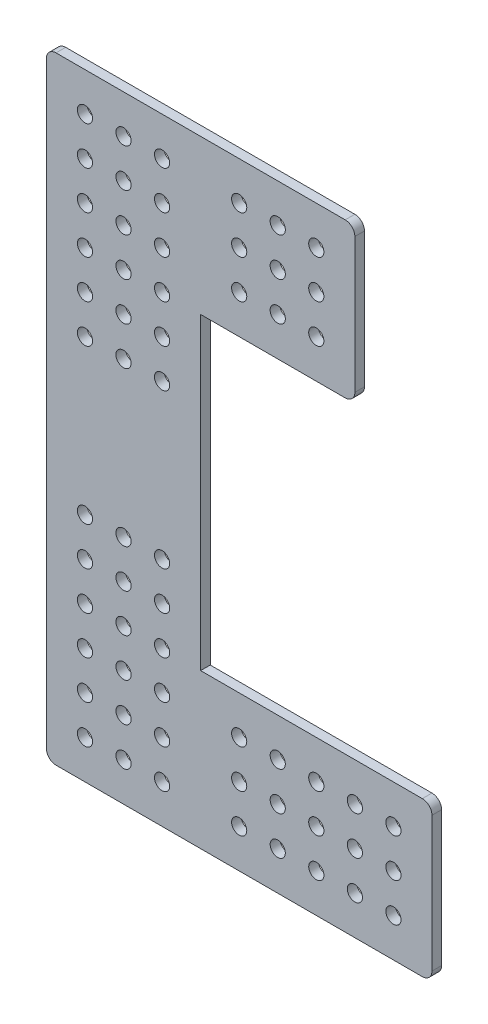
from build123d import *

# Parameters (mm, degrees)
BOSS_EXTRUDE1_DEPTH = 3.175
SKETCH2_R           = 2.5
CUT_EXTRUDE1_DEPTH  = 4.175
BOSS_EXTRUDE2_DEPTH = 3.175
SKETCH4_R           = 2.505
CUT_EXTRUDE2_DEPTH  = 4.175


with BuildPart() as part:
    # Sketch1 → Boss-Extrude1 (new body)
    with BuildSketch(Plane.XY):
        with BuildLine():
            Line((26.334969325, 167.047852761), (23.159969325, 167.047852761))
            Line((23.159969325, 167.047852761), (-21.290030675, 167.047852761))
            ThreePointArc((-21.290030675, 167.047852761), (-23.535094705, 166.117916791), (-24.465030675, 163.872852761))
            Line((-24.465030675, 163.872852761), (-24.465030675, 14.647852761))
            Line((-24.465030675, 14.647852761), (26.334969325, 14.647852761))
            Line((26.334969325, 14.647852761), (26.334969325, 163.872852761))
            Line((26.334969325, 163.872852761), (26.334969325, 167.047852761))
        make_face()
        with BuildLine():
            Line((99.359969325, 14.647852761), (26.334969325, 14.647852761))
            Line((26.334969325, 14.647852761), (-24.465030675, 14.647852761))
            Line((-24.465030675, 14.647852761), (-24.465030675, -32.977147239))
            ThreePointArc((-24.465030675, -32.977147239), (-23.535094705, -35.22221127), (-21.290030675, -36.152147239))
            Line((-21.290030675, -36.152147239), (99.359969325, -36.152147239))
            ThreePointArc((99.359969325, -36.152147239), (101.605033355, -35.22221127), (102.534969325, -32.977147239))
            Line((102.534969325, -32.977147239), (102.534969325, 11.472852761))
            ThreePointArc((102.534969325, 11.472852761), (101.605033355, 13.717916791), (99.359969325, 14.647852761))
        make_face()
    extrude(amount=BOSS_EXTRUDE1_DEPTH)

    # Sketch2 → Cut-Extrude1 (cut, through all)
    with BuildSketch(Plane.XY.offset(3.175)):
        with Locations((-11.765030675, 154.347852761)):
            Circle(SKETCH2_R)
        with Locations((89.834969325, -23.452147239)):
            Circle(SKETCH2_R)
        with Locations((0.934969325, 154.347852761)):
            Circle(SKETCH2_R)
        with Locations((13.634969325, 154.347852761)):
            Circle(SKETCH2_R)
        with Locations((0.934969325, 141.647852761)):
            Circle(SKETCH2_R)
        with Locations((13.634969325, 141.647852761)):
            Circle(SKETCH2_R)
        with Locations((0.934969325, 128.947852761)):
            Circle(SKETCH2_R)
        with Locations((13.634969325, 128.947852761)):
            Circle(SKETCH2_R)
        with Locations((0.934969325, 116.247852761)):
            Circle(SKETCH2_R)
        with Locations((13.634969325, 116.247852761)):
            Circle(SKETCH2_R)
        with Locations((0.934969325, 103.547852761)):
            Circle(SKETCH2_R)
        with Locations((13.634969325, 103.547852761)):
            Circle(SKETCH2_R)
        with Locations((0.934969325, 90.847852761)):
            Circle(SKETCH2_R)
        with Locations((13.634969325, 90.847852761)):
            Circle(SKETCH2_R)
        with Locations((-11.765030675, 141.647852761)):
            Circle(SKETCH2_R)
        with Locations((-11.765030675, 128.947852761)):
            Circle(SKETCH2_R)
        with Locations((-11.765030675, 116.247852761)):
            Circle(SKETCH2_R)
        with Locations((-11.765030675, 103.547852761)):
            Circle(SKETCH2_R)
        with Locations((-11.765030675, 90.847852761)):
            Circle(SKETCH2_R)
        with Locations((77.134969325, -23.452147239)):
            Circle(SKETCH2_R)
        with Locations((64.434969325, -23.452147239)):
            Circle(SKETCH2_R)
        with Locations((51.734969325, -23.452147239)):
            Circle(SKETCH2_R)
        with Locations((39.034969325, -23.452147239)):
            Circle(SKETCH2_R)
        with Locations((77.134969325, -10.752147239)):
            Circle(SKETCH2_R)
        with Locations((64.434969325, -10.752147239)):
            Circle(SKETCH2_R)
        with Locations((51.734969325, -10.752147239)):
            Circle(SKETCH2_R)
        with Locations((39.034969325, -10.752147239)):
            Circle(SKETCH2_R)
        with Locations((77.134969325, 1.947852761)):
            Circle(SKETCH2_R)
        with Locations((64.434969325, 1.947852761)):
            Circle(SKETCH2_R)
        with Locations((51.734969325, 1.947852761)):
            Circle(SKETCH2_R)
        with Locations((39.034969325, 1.947852761)):
            Circle(SKETCH2_R)
        with Locations((89.834969325, -10.752147239)):
            Circle(SKETCH2_R)
        with Locations((89.834969325, 1.947852761)):
            Circle(SKETCH2_R)
        with Locations((-11.765030675, 40.047852761)):
            Circle(SKETCH2_R)
        with Locations((0.934969325, 40.047852761)):
            Circle(SKETCH2_R)
        with Locations((13.634969325, 40.047852761)):
            Circle(SKETCH2_R)
        with Locations((-11.765030675, 27.347852761)):
            Circle(SKETCH2_R)
        with Locations((0.934969325, 27.347852761)):
            Circle(SKETCH2_R)
        with Locations((13.634969325, 27.347852761)):
            Circle(SKETCH2_R)
        with Locations((-11.765030675, 14.647852761)):
            Circle(SKETCH2_R)
        with Locations((0.934969325, 14.647852761)):
            Circle(SKETCH2_R)
        with Locations((13.634969325, 14.647852761)):
            Circle(SKETCH2_R)
        with Locations((-11.765030675, 1.947852761)):
            Circle(SKETCH2_R)
        with Locations((0.934969325, 1.947852761)):
            Circle(SKETCH2_R)
        with Locations((13.634969325, 1.947852761)):
            Circle(SKETCH2_R)
        with Locations((-11.765030675, -10.752147239)):
            Circle(SKETCH2_R)
        with Locations((0.934969325, -10.752147239)):
            Circle(SKETCH2_R)
        with Locations((13.634969325, -10.752147239)):
            Circle(SKETCH2_R)
        with Locations((-11.765030675, -23.452147239)):
            Circle(SKETCH2_R)
        with Locations((0.934969325, -23.452147239)):
            Circle(SKETCH2_R)
        with Locations((13.634969325, -23.452147239)):
            Circle(SKETCH2_R)
    extrude(amount=-CUT_EXTRUDE1_DEPTH, mode=Mode.SUBTRACT)

    # Sketch3 → Boss-Extrude2 (add)
    with BuildSketch(Plane.XY.offset(3.175)):
        with BuildLine():
            Line((73.959969325, 167.047852761), (26.334969325, 167.047852761))
            Line((26.334969325, 167.047852761), (26.334969325, 116.247852761))
            Line((26.334969325, 116.247852761), (73.959969325, 116.247852761))
            ThreePointArc((73.959969325, 116.247852761), (76.205033355, 117.17778873), (77.134969325, 119.422852761))
            Line((77.134969325, 119.422852761), (77.134969325, 163.872852761))
            ThreePointArc((77.134969325, 163.872852761), (76.205033355, 166.117916791), (73.959969325, 167.047852761))
        make_face()
    extrude(amount=-BOSS_EXTRUDE2_DEPTH)

    # Sketch4 → Cut-Extrude2 (cut, through all)
    with BuildSketch(Plane.XY.offset(3.175)):
        with Locations((64.434969325, 154.347852761)):
            Circle(SKETCH4_R)
        with Locations((51.734969325, 154.347852761)):
            Circle(SKETCH4_R)
        with Locations((39.034969325, 154.347852761)):
            Circle(SKETCH4_R)
        with Locations((51.734969325, 141.647852761)):
            Circle(SKETCH4_R)
        with Locations((39.034969325, 141.647852761)):
            Circle(SKETCH4_R)
        with Locations((51.734969325, 128.947852761)):
            Circle(SKETCH4_R)
        with Locations((39.034969325, 128.947852761)):
            Circle(SKETCH4_R)
        with Locations((64.434969325, 141.647852761)):
            Circle(SKETCH4_R)
        with Locations((64.434969325, 128.947852761)):
            Circle(SKETCH4_R)
    extrude(amount=-CUT_EXTRUDE2_DEPTH, mode=Mode.SUBTRACT)


solid = part.part
